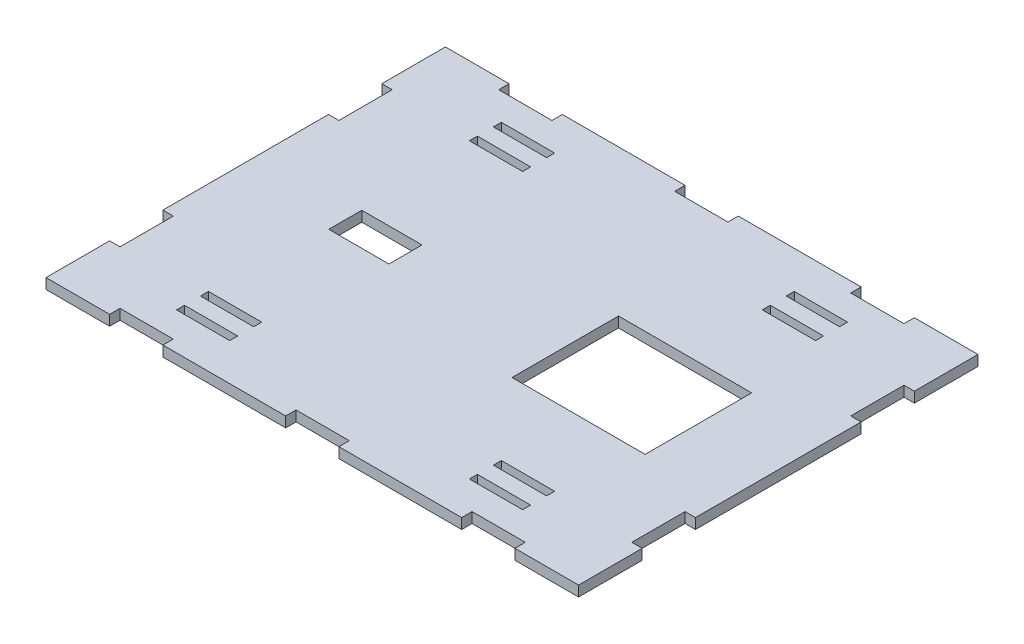
from build123d import *

# Parameters (mm, degrees)
SKETCH1_W           = 20
SKETCH1_H           = 3
SKETCH1_W_2         = 50
SKETCH1_H_2         = 40
SKETCH1_W_3         = 22.6
SKETCH1_H_3         = 12.4
BOSS_EXTRUDE1_DEPTH = 3.9


with BuildPart() as part:
    # Sketch1 → Boss-Extrude1 (new body)
    with BuildSketch(Plane(origin=(0, 0, 0), x_dir=(1, 0, 0), z_dir=(0, 1, 0))):
        Polygon((-100, 75), (-76.1, 75), (-76.1, 71.1), (-56.1, 71.1), (-56.1, 75), (-10, 75), (-10, 71.1), (10, 71.1), (10, 75), (56.1, 75), (56.1, 71.1), (76.1, 71.1), (76.1, 75), (100, 75), (100, 51.1), (96.1, 51.1), (96.1, 31.1), (100, 31.1), (100, -31.1), (96.1, -31.1), (96.1, -51.1), (100, -51.1), (100, -75), (76.1, -75), (76.1, -71.1), (56.1, -71.1), (56.1, -75), (10, -75), (10, -71.1), (-10, -71.1), (-10, -75), (-56.1, -75), (-56.1, -71.1), (-76.1, -71.1), (-76.1, -75), (-100, -75), (-100, -51.1), (-96.1, -51.1), (-96.1, -31.1), (-100, -31.1), (-100, 31.1), (-96.1, 31.1), (-96.1, 51.1), (-100, 51.1), align=None)
        with Locations((-55, -50.5)):
            Rectangle(SKETCH1_W, SKETCH1_H, mode=Mode.SUBTRACT)
        with Locations((-55, -59.5)):
            Rectangle(SKETCH1_W, SKETCH1_H, mode=Mode.SUBTRACT)
        with Locations((45, 0)):
            Rectangle(SKETCH1_W_2, SKETCH1_H_2, mode=Mode.SUBTRACT)
        with Locations((55, -59.5)):
            Rectangle(SKETCH1_W, SKETCH1_H, mode=Mode.SUBTRACT)
        with Locations((55, -50.5)):
            Rectangle(SKETCH1_W, SKETCH1_H, mode=Mode.SUBTRACT)
        with Locations((55, 50.5)):
            Rectangle(SKETCH1_W, SKETCH1_H, mode=Mode.SUBTRACT)
        with Locations((55, 59.5)):
            Rectangle(SKETCH1_W, SKETCH1_H, mode=Mode.SUBTRACT)
        with Locations((-55, 59.5)):
            Rectangle(SKETCH1_W, SKETCH1_H, mode=Mode.SUBTRACT)
        with Locations((-55, 50.5)):
            Rectangle(SKETCH1_W, SKETCH1_H, mode=Mode.SUBTRACT)
        with Locations((-51.3, 0)):
            Rectangle(SKETCH1_W_3, SKETCH1_H_3, mode=Mode.SUBTRACT)
    extrude(amount=BOSS_EXTRUDE1_DEPTH)


solid = part.part
